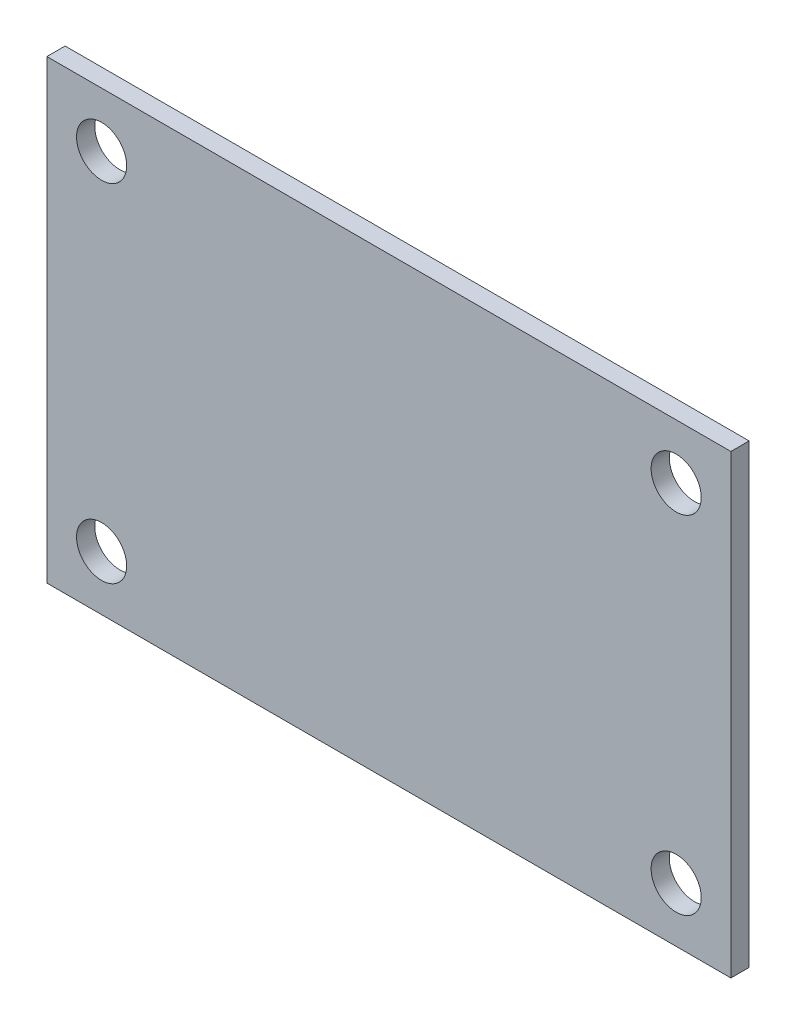
from build123d import *

# Parameters (mm, degrees)
SZKIC1_W                             = 150
SZKIC1_H                             = 100
DODANIE_WYCI_GNI_CIE1_DEPTH          = 4
OTW_R_POD_RUB_M101_D                 = 11
LUSTRO1_AT_THE_SECOND_PLANE_COPY_1_D = 11


with BuildPart() as part:
    # Szkic1 → Dodanie-wyciągnięcie1 (new body)
    with BuildSketch(Plane.XY):
        Rectangle(SZKIC1_W, SZKIC1_H)
    extrude(amount=DODANIE_WYCI_GNI_CIE1_DEPTH)

    # Otwór pod śrubę M101 (through all)
    with Locations(Plane.XY.offset(4)):
        with Locations((-63, 38)):
            otw_r_pod_rub_m101 = Hole(OTW_R_POD_RUB_M101_D / 2)

    # Lustro1: Otwór pod śrubę M101 across plane
    add(otw_r_pod_rub_m101.mirror(Plane.ZX), mode=Mode.SUBTRACT)

    # Lustro1 at the second plane: Otwór pod śrubę M101 across plane
    add(otw_r_pod_rub_m101.mirror(Plane(origin=(0, 0, 0), x_dir=(0, 0, 1), z_dir=(1, 0, 0))), mode=Mode.SUBTRACT)

    # Lustro1 at the second plane copy 1 (through all)
    with Locations(Plane(origin=(0, 0, 4), x_dir=(-1, 0, 0), z_dir=(0, 0, 1))):
        with Locations((-63, 38)):
            Hole(LUSTRO1_AT_THE_SECOND_PLANE_COPY_1_D / 2)


solid = part.part
